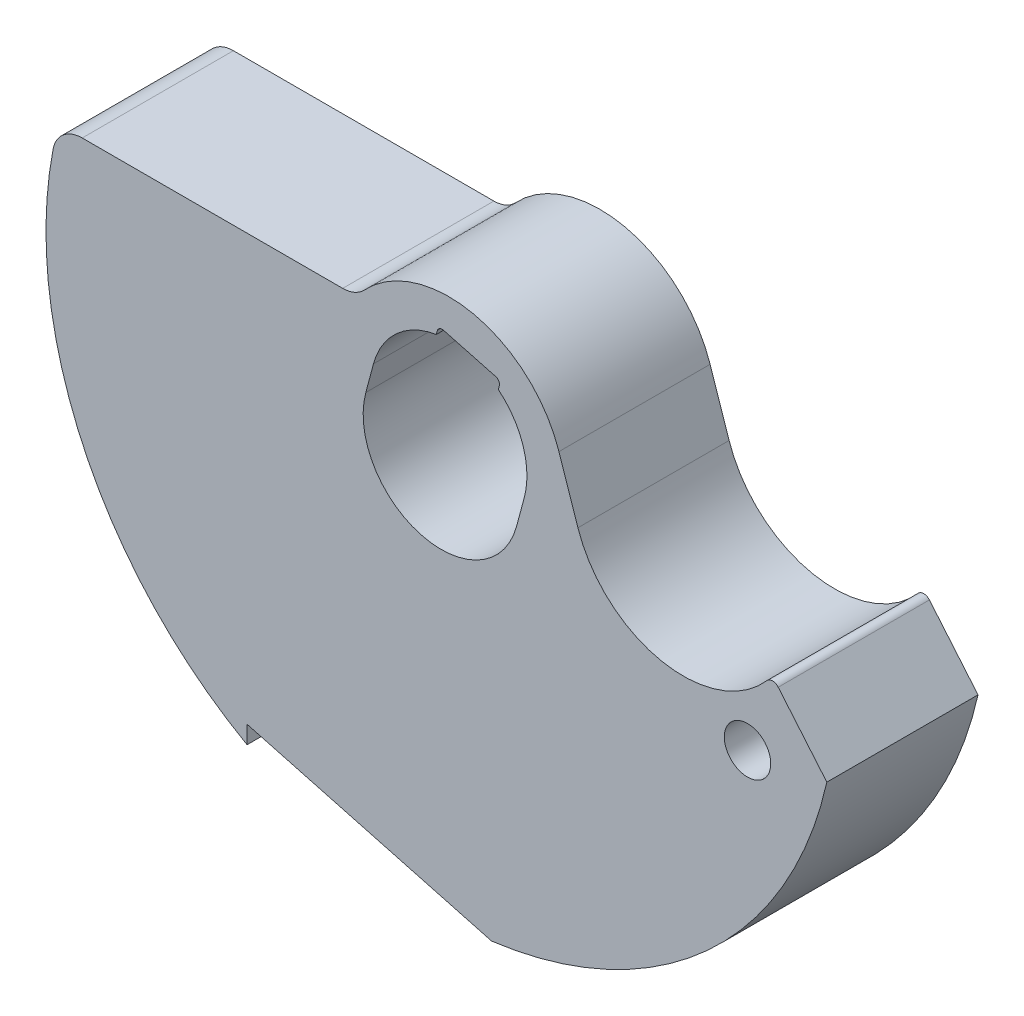
from build123d import *

# Parameters (mm, degrees)
SKETCH1_R           = 1.1938
BOSS_EXTRUDE1_DEPTH = 7.7724


with BuildPart() as part:
    # Sketch1 → Boss-Extrude1 (new body)
    with BuildSketch(Plane.XY):
        with BuildLine():
            Line((-5.065262452, 5.08), (-18.456556559, 5.08))
            ThreePointArc((-18.456556559, 5.08), (-19.426909517, 4.731155792), (-19.953034117, 3.844324324))
            ThreePointArc((-19.953034117, 3.844324324), (-18.44069754, -8.534815418), (-9.9822, -17.699098371))
            Line((-9.9822, -17.699098371), (-9.9822, -16.784328658))
            Line((-9.9822, -16.784328658), (2.593084415, -20.153865962))
            ThreePointArc((2.593084415, -20.153865962), (13.682234942, -15.023276839), (19.824330155, -4.46075486))
            Line((19.824330155, -4.46075486), (17.325781624, -1.483100672))
            ThreePointArc((17.325781624, -1.483100672), (17.037851626, -1.347023051), (16.747173773, -1.477127579))
            ThreePointArc((16.747173773, -1.477127579), (11.324901076, -3.317959511), (7.028137334, 0.467212181))
            Line((7.028137334, 0.467212181), (6.053096787, 3.371693793))
            ThreePointArc((6.053096787, 3.371693793), (1.669604011, 7.303273092), (-3.95481445, 5.560217822))
            ThreePointArc((-3.95481445, 5.560217822), (-4.460344292, 5.205196933), (-5.065262452, 5.08))
        make_face()
        with Locations((15.748, -5.08)):
            Circle(SKETCH1_R, mode=Mode.SUBTRACT)
        with BuildLine():
            Line((-3.876453526, 1.038692592), (-3.482013301, 2.510763551))
            ThreePointArc((-3.482013301, 2.510763551), (-2.298514325, 4.447599489), (-0.253578298, 5.432607064))
            Line((-0.253578298, 5.432607064), (-0.201054745, 5.628627633))
            ThreePointArc((-0.201054745, 5.628627633), (-0.082709585, 5.782858048), (0.110030452, 5.808232755))
            Line((0.110030452, 5.808232755), (2.808827211, 5.085092343))
            ThreePointArc((2.808827211, 5.085092343), (2.963057626, 4.966747183), (2.988432333, 4.774007146))
            Line((2.988432333, 4.774007146), (2.93590878, 4.577986577))
            ThreePointArc((2.93590878, 4.577986577), (4.214371541, 2.702476981), (4.270893751, 0.433378367))
            Line((4.270893751, 0.433378367), (3.876453526, -1.038692592))
            ThreePointArc((3.876453526, -1.038692592), (-1.038692592, -3.876453526), (-3.876453526, 1.038692592))
        make_face(mode=Mode.SUBTRACT)
    extrude(amount=-BOSS_EXTRUDE1_DEPTH)


solid = part.part
